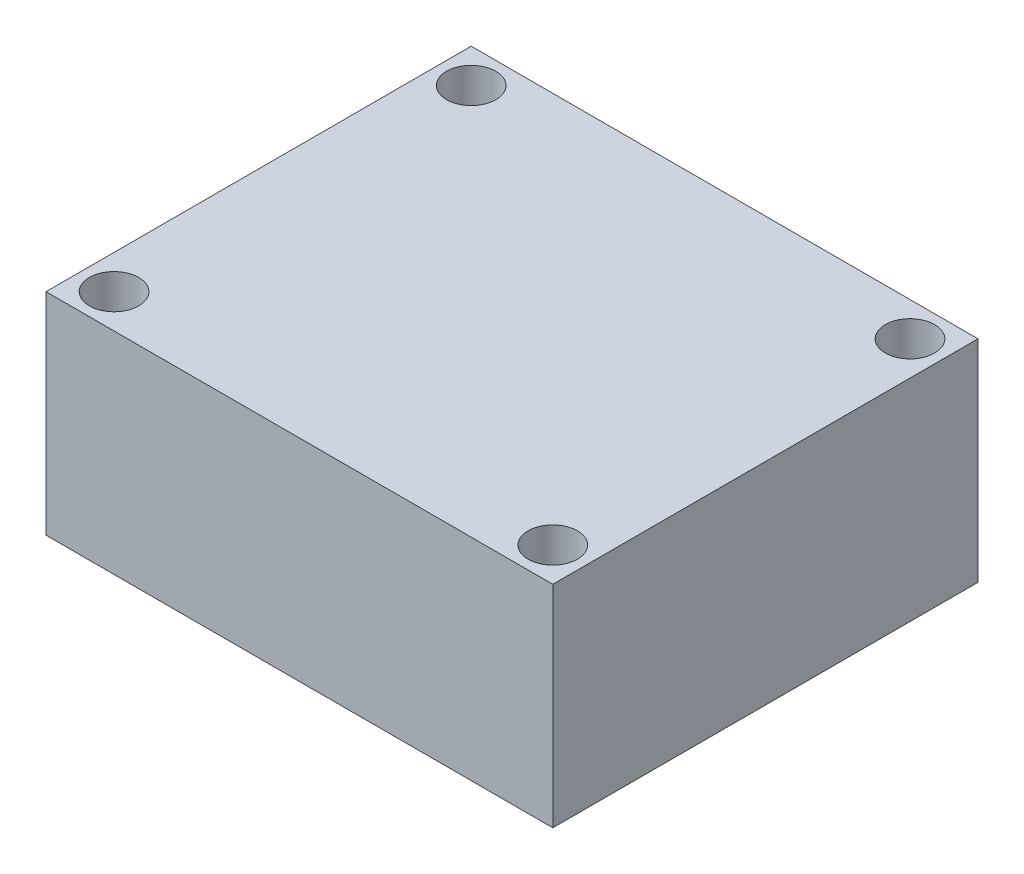
from build123d import *

# Parameters (mm, degrees)
SKETCH1_W           = 37.846
SKETCH1_H           = 31.75
BOSS_EXTRUDE1_DEPTH = 7.874
SKETCH2_R           = 1.8415
CUT_EXTRUDE1_DEPTH  = 16.748


with BuildPart() as part:
    # Sketch1 → Boss-Extrude1 (new body, symmetric)
    with BuildSketch(Plane(origin=(0, 0, 0), x_dir=(1, 0, 0), z_dir=(0, 1, 0))):
        Rectangle(SKETCH1_W, SKETCH1_H)
    extrude(amount=BOSS_EXTRUDE1_DEPTH, both=True)

    # Sketch2 → Cut-Extrude1 (cut, through all)
    with BuildSketch(Plane.XZ.offset(7.874)):
        with Locations((-16.383, 13.335)):
            Circle(SKETCH2_R)
        with Locations((16.383, 13.335)):
            Circle(SKETCH2_R)
        with Locations((16.383, -13.335)):
            Circle(SKETCH2_R)
        with Locations((-16.383, -13.335)):
            Circle(SKETCH2_R)
    extrude(amount=-CUT_EXTRUDE1_DEPTH, mode=Mode.SUBTRACT)


solid = part.part
